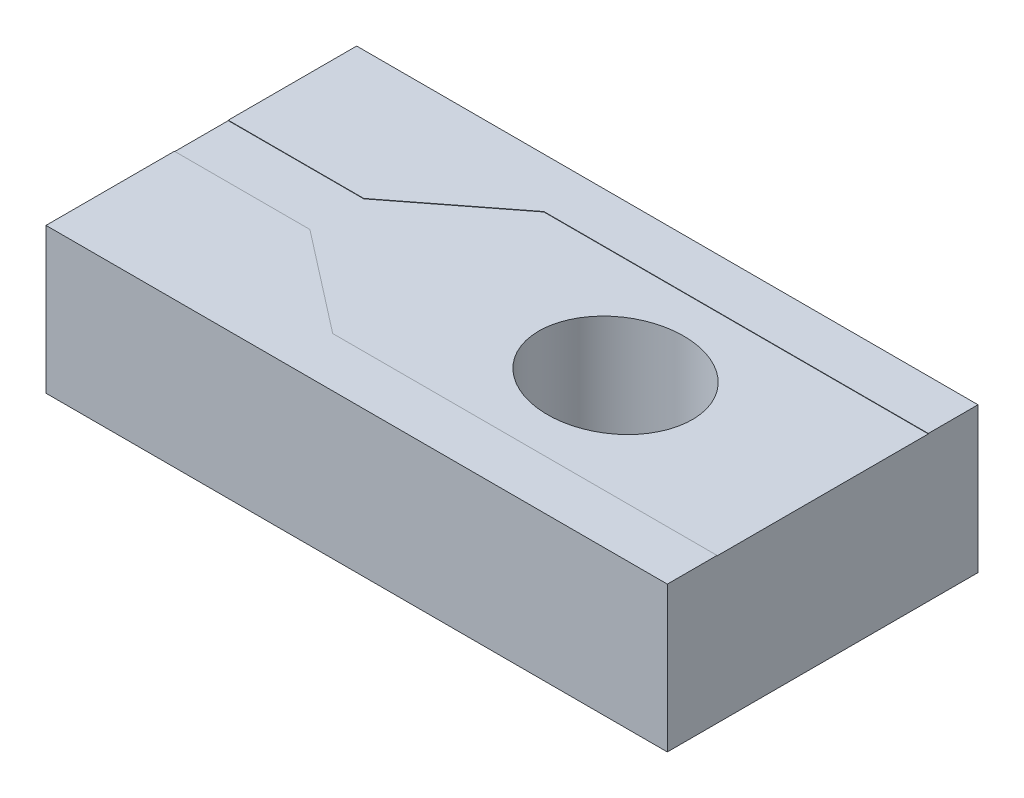
from build123d import *

# Parameters (mm, degrees)
SKETCH1_W           = 300
SKETCH1_H           = 150
SKETCH1_RX          = 37.075
SKETCH1_RY          = 32.9
BOSS_EXTRUDE1_DEPTH = 70
BOSS_EXTRUDE2_DEPTH = 0.2


with BuildPart() as part:
    # Sketch1 → Boss-Extrude1 (new body)
    with BuildSketch(Plane(origin=(0, 0, 0), x_dir=(1, 0, 0), z_dir=(0, 1, 0))):
        with Locations((-50, 0)):
            Rectangle(SKETCH1_W, SKETCH1_H)
        with Locations(Location((0, 0), (0, 0, 180))):
            Ellipse(SKETCH1_RX, SKETCH1_RY, mode=Mode.SUBTRACT)
    extrude(amount=BOSS_EXTRUDE1_DEPTH)

    # Sketch2 → Boss-Extrude2 (add)
    with BuildSketch(Plane(origin=(0, 70, 0), x_dir=(1, 0, 0), z_dir=(0, 1, 0))):
        Polygon((100, 51), (-85.575, 51), (-134.575, 13), (-200, 13), (-200, 75), (100, 75), align=None)
        Polygon((-200, -13), (-134.575, -13), (-85.575, -51), (100, -51), (100, -75), (-200, -75), align=None)
    extrude(amount=BOSS_EXTRUDE2_DEPTH)


solid = part.part
